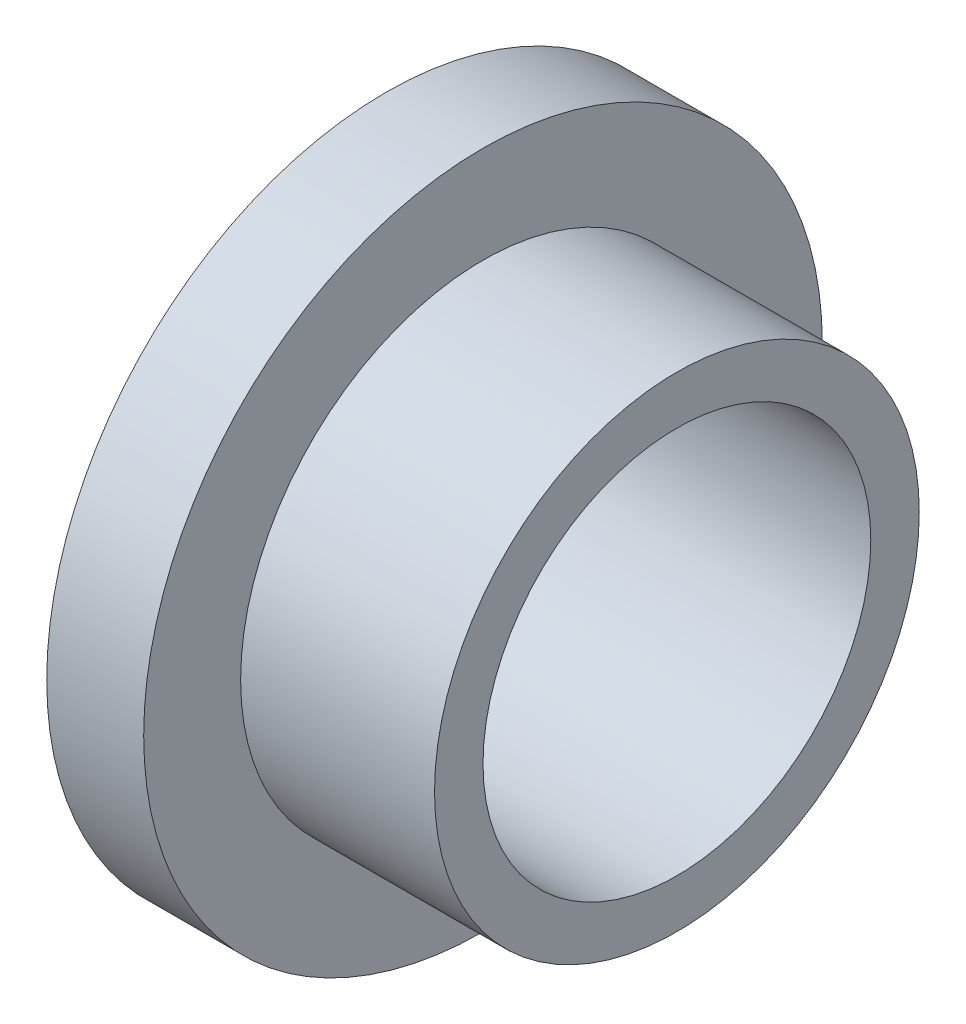
from build123d import *

# Parameters (mm, degrees)
SKETCH1_R           = 7.9375
SKETCH1_R_2         = 6.35
BOSS_EXTRUDE1_DEPTH = 9.525
SKETCH2_R           = 11.1125
SKETCH2_R_2         = 6.35
BOSS_EXTRUDE2_DEPTH = 3.175


with BuildPart() as part:
    # Sketch1 → Boss-Extrude1 (new body)
    with BuildSketch(Plane(origin=(0, 0, 0), x_dir=(0, 0, -1), z_dir=(1, 0, 0))):
        Circle(SKETCH1_R)
        Circle(SKETCH1_R_2, mode=Mode.SUBTRACT)
    extrude(amount=BOSS_EXTRUDE1_DEPTH)

    # Sketch2 → Boss-Extrude2 (add)
    with BuildSketch(Plane.ZY):
        Circle(SKETCH2_R)
        Circle(SKETCH2_R_2, mode=Mode.SUBTRACT)
    extrude(amount=-BOSS_EXTRUDE2_DEPTH)


solid = part.part
